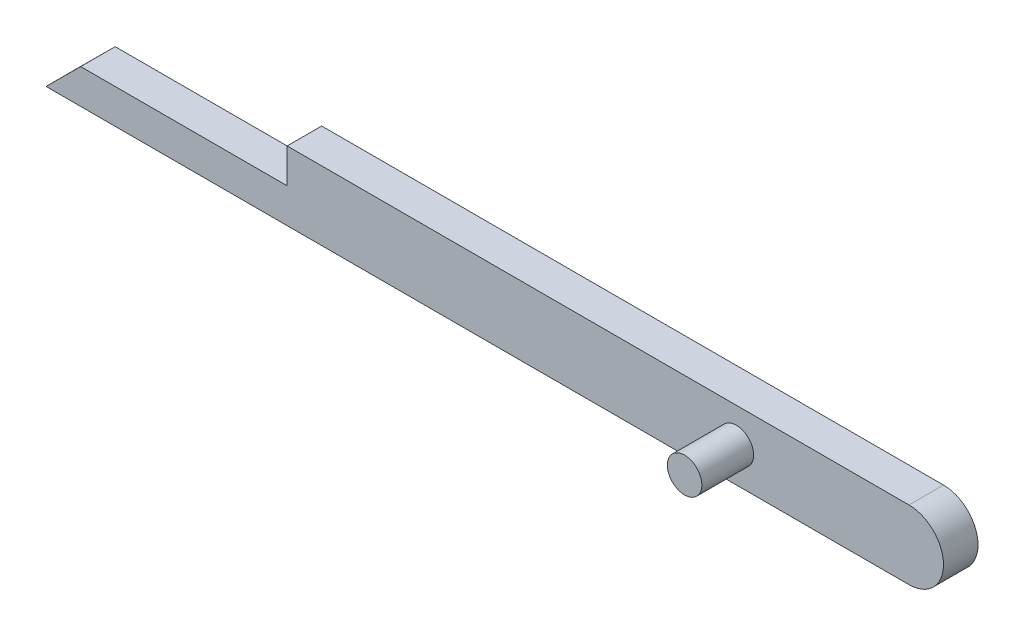
from build123d import *

# Parameters (mm, degrees)
SKETCH1_R           = 10
BOSS_EXTRUDE1_DEPTH = 20
SKETCH1_2_R         = 10
BOSS_EXTRUDE2_DEPTH = 50


with BuildPart() as part:
    # Sketch1 → Boss-Extrude1 (new body)
    with BuildSketch(Plane.XY):
        with BuildLine():
            Line((-229.914228229, 0), (-110.283225042, 0))
            Line((-110.283225042, 0), (-110.283225042, 20))
            Line((-110.283225042, 20), (250, 20))
            ThreePointArc((250, 20), (270, 0), (250, -20))
            Line((250, -20), (-250, -20))
            Line((-250, -20), (-229.914228229, 0))
        make_face()
        with Locations((150, 0)):
            Circle(SKETCH1_R, mode=Mode.SUBTRACT)
    extrude(amount=BOSS_EXTRUDE1_DEPTH)

    # Sketch1_2 → Boss-Extrude2 (add)
    with BuildSketch(Plane.XY):
        with Locations((150, 0)):
            Circle(SKETCH1_2_R)
    extrude(amount=BOSS_EXTRUDE2_DEPTH)


solid = part.part
